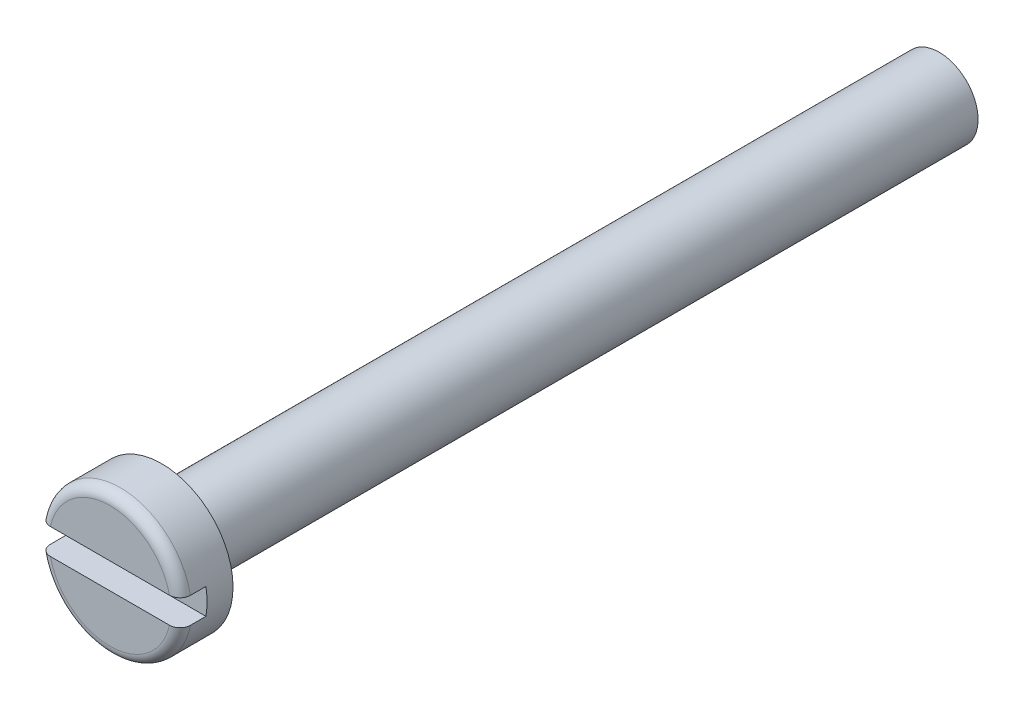
from build123d import *

# Parameters (mm, degrees)
SKETCH1_R           = 2.75
BOSS_EXTRUDE1_DEPTH = 2
FILLET1_R           = 0.4
SKETCH2_W           = 7.85101285
SKETCH2_H           = 1
CUT_EXTRUDE1_DEPTH  = 1
SKETCH3_R           = 1.5
BOSS_EXTRUDE2_DEPTH = 30


with BuildPart() as part:
    # Sketch1 → Boss-Extrude1 (new body)
    with BuildSketch(Plane.XY):
        Circle(SKETCH1_R)
    extrude(amount=BOSS_EXTRUDE1_DEPTH)

    # Fillet1
    fillet1_edges = [part.edges().sort_by_distance(p)[0] for p in [
        (-2.75, 0, 2),
    ]]
    fillet(fillet1_edges, radius=FILLET1_R)

    # Sketch2 → Cut-Extrude1 (cut)
    with BuildSketch(Plane.XY.offset(2)):
        Rectangle(SKETCH2_W, SKETCH2_H)
    extrude(amount=-CUT_EXTRUDE1_DEPTH, mode=Mode.SUBTRACT)

    # Sketch3 → Boss-Extrude2 (add)
    with BuildSketch(Plane(origin=(0, 0, 0), x_dir=(-1, 0, 0), z_dir=(0, 0, -1))):
        Circle(SKETCH3_R)
    extrude(amount=BOSS_EXTRUDE2_DEPTH)


solid = part.part
